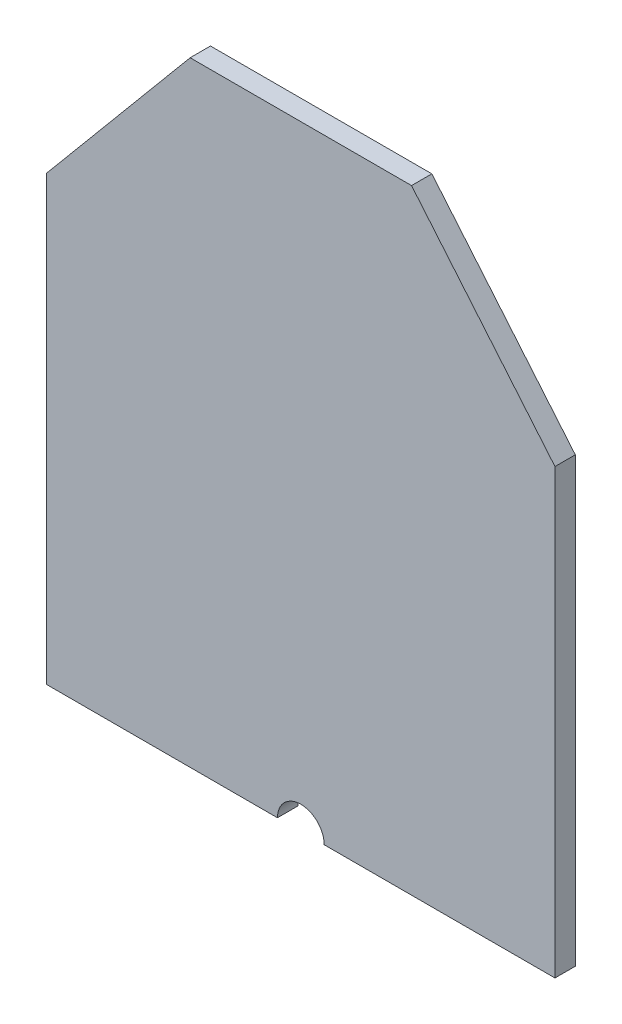
from build123d import *

# Parameters (mm, degrees)
BOSS_EXTRUDE2_DEPTH = 5


with BuildPart() as part:
    # Sketch1 → Boss-Extrude2 (new body, symmetric)
    with BuildSketch(Plane.XY):
        with BuildLine():
            Line((-11.5, -108.94), (-125, -108.94))
            Line((-125, -108.94), (-125, 108.94))
            Line((-125, 108.94), (-54.45, 193.35))
            Line((-54.45, 193.35), (54.45, 193.35))
            Line((54.45, 193.35), (125, 108.94))
            Line((125, 108.94), (125, -108.94))
            Line((125, -108.94), (11.5, -108.94))
            ThreePointArc((11.5, -108.94), (0, -97.44), (-11.5, -108.94))
        make_face()
    extrude(amount=BOSS_EXTRUDE2_DEPTH, both=True)


solid = part.part
